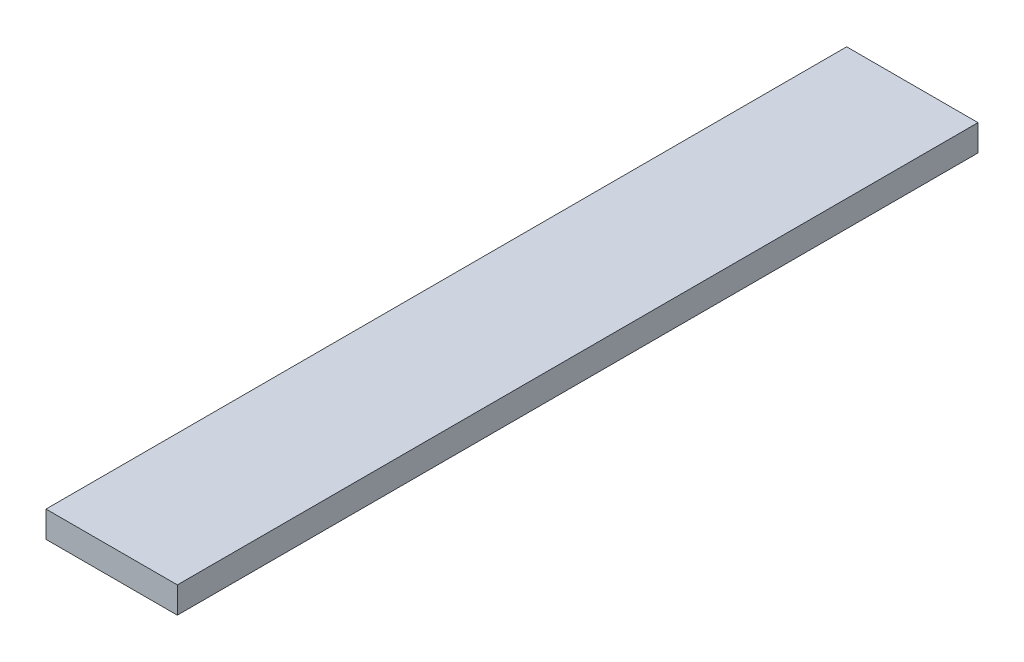
from build123d import *

# Parameters (mm, degrees)
SKETCH3_W           = 50
SKETCH3_H           = 10
BOSS_EXTRUDE1_DEPTH = 152.4


with BuildPart() as part:
    # Sketch3 → Boss-Extrude1 (new, symmetric)
    with BuildSketch(Plane.XY):
        Rectangle(SKETCH3_W, SKETCH3_H)
    extrude(amount=BOSS_EXTRUDE1_DEPTH, both=True)


solid = part.part
